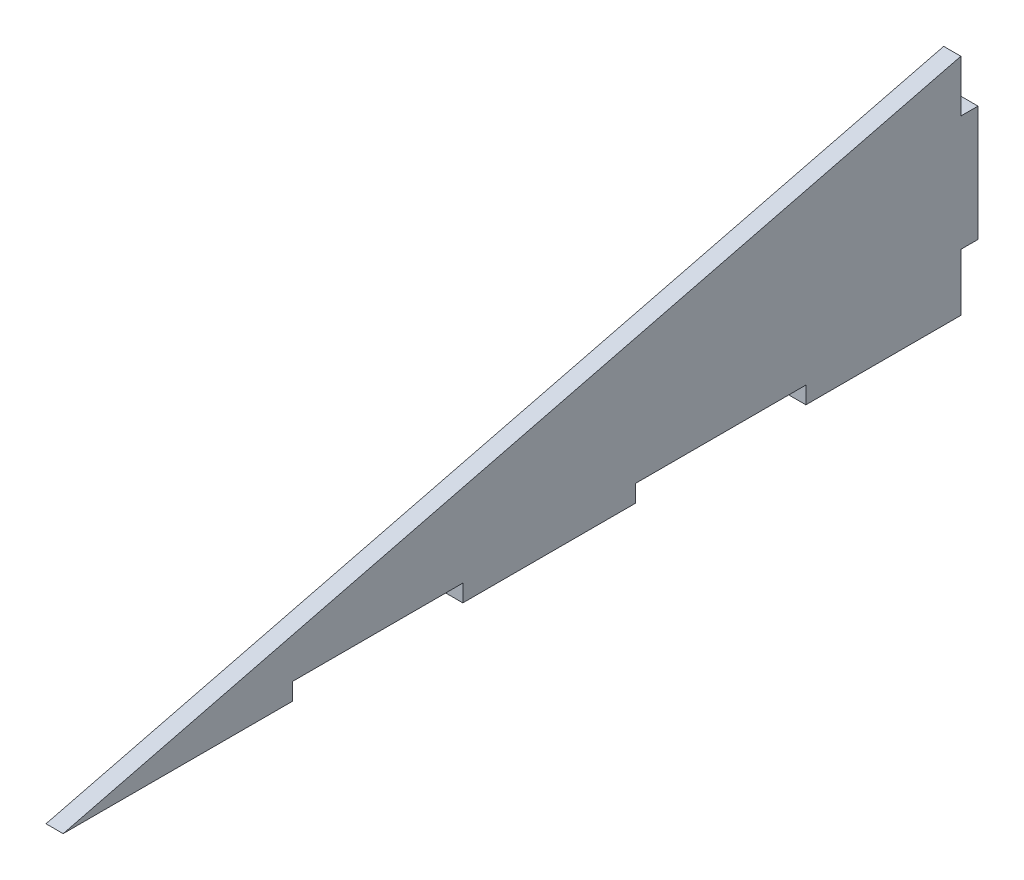
from build123d import *

# Parameters (mm, degrees)
BOSS_EXTRUDE1_DEPTH = 3


with BuildPart() as part:
    # Sketch2 → Boss-Extrude1 (new body)
    with BuildSketch(Plane(origin=(0, 0, 0), x_dir=(0, 0, -1), z_dir=(1, 0, 0))):
        Polygon((157, 39.25), (0, 0), (40.1, 0), (40.1, 3), (69.9, 3), (69.9, 0), (100.1, 0), (100.1, 3), (129.9, 3), (129.9, 0), (157, 0), (157, 10), (160, 10), (160, 30.2), (157, 30.2), align=None)
    extrude(amount=BOSS_EXTRUDE1_DEPTH)


solid = part.part
